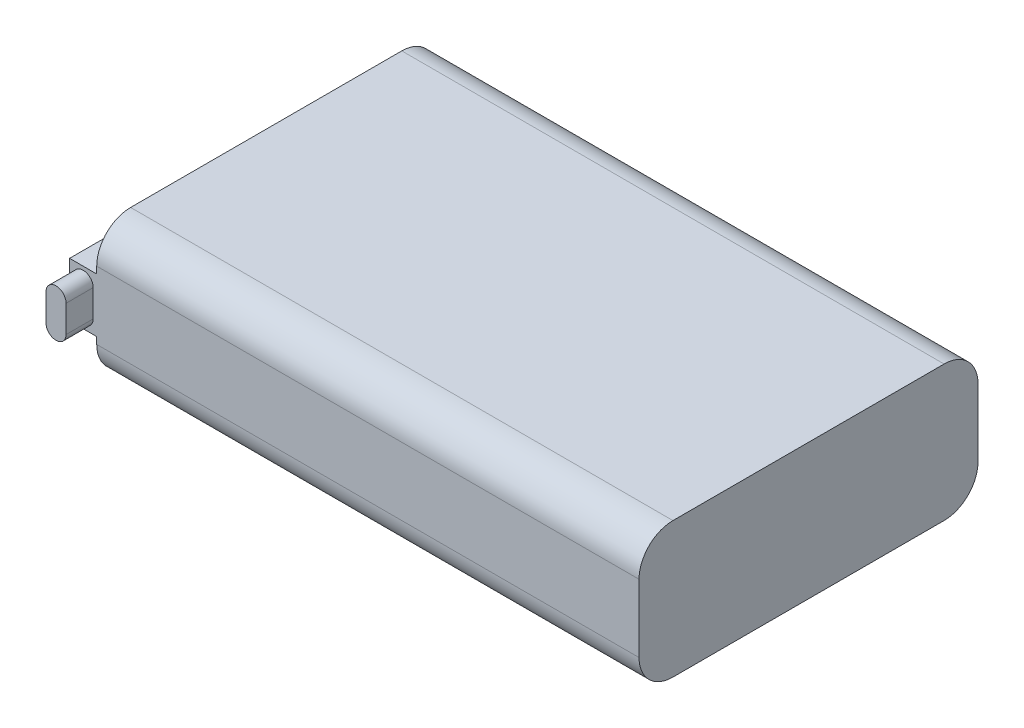
from build123d import *

# Parameters (mm, degrees)
SKETCH_1_W      = 40
SKETCH_1_H      = 25
EXTRUDE_1_DEPTH = 10
FILLET_1_R      = 2.5
SKETCH_2_W      = 25
SKETCH_2_H      = 4
EXTRUDE_2_DEPTH = 2
EXTRUDE_3_DEPTH = 2


with BuildPart() as part:
    # 草图1 → 凸台-拉伸1 (new body)
    with BuildSketch(Plane(origin=(0, 0, 0), x_dir=(1, 0, 0), z_dir=(0, 1, 0))):
        with Locations((20, 12.5)):
            Rectangle(SKETCH_1_W, SKETCH_1_H)
    extrude(amount=EXTRUDE_1_DEPTH)

    # 圆角1
    fillet_1_edges = [part.edges().sort_by_distance(p)[0] for p in [
        (20, 10, -25),
        (20, 0, -25),
        (20, 0, 0),
        (20, 10, 0),
    ]]
    fillet(fillet_1_edges, radius=FILLET_1_R)

    # 草图2 → 凸台-拉伸2 (add)
    with BuildSketch(Plane.ZY):
        with Locations((-12.5, 5)):
            Rectangle(SKETCH_2_W, SKETCH_2_H)
    extrude(amount=EXTRUDE_2_DEPTH)

    # 草图3 → 凸台-拉伸3 (add)
    with BuildSketch(Plane.XY):
        with BuildLine():
            Line((-0.26, 6), (-0.26, 4))
            ThreePointArc((-0.26, 4), (-1, 3.26), (-1.74, 4))
            Line((-1.74, 4), (-1.74, 6))
            ThreePointArc((-1.74, 6), (-1, 6.74), (-0.26, 6))
        make_face()
    extrude(amount=EXTRUDE_3_DEPTH)


solid = part.part
